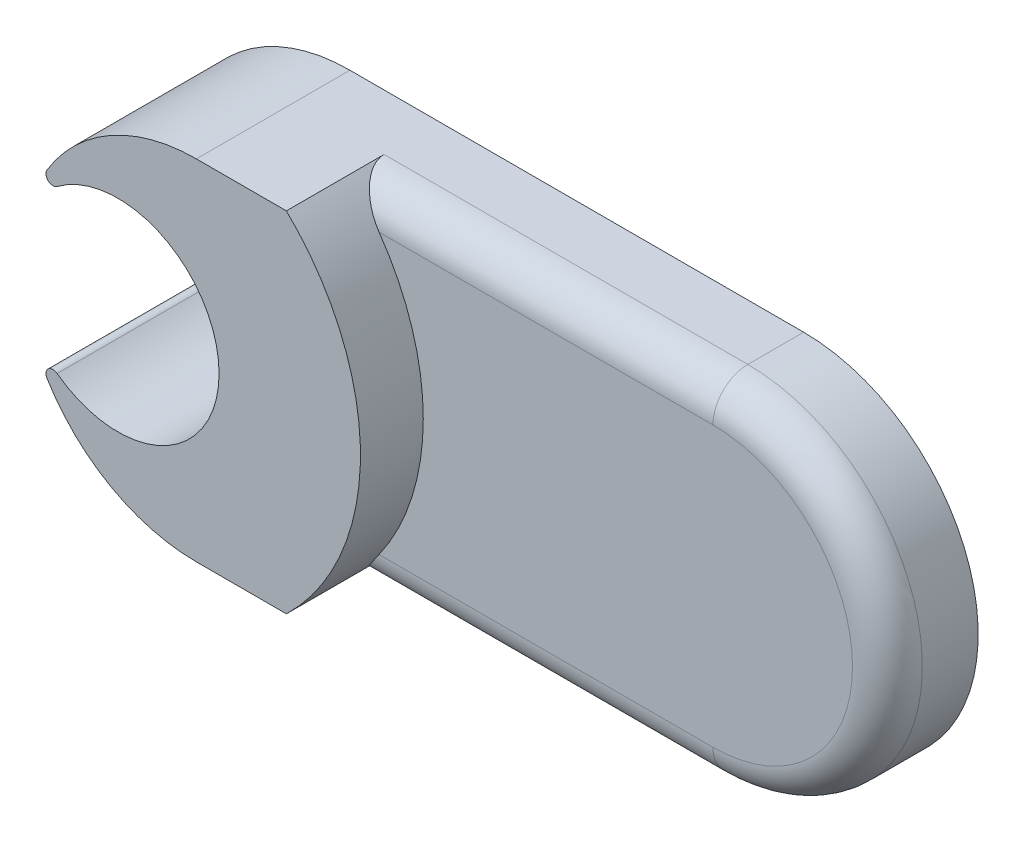
from build123d import *

# Parameters (mm, degrees)
BOSS_EXTRUDE7_DEPTH  = 2.5
BOSS_EXTRUDE8_DEPTH  = 4.4
FILLET1_R            = 0.2
FILLET2_R            = 0.2
BOSS_EXTRUDE9_DEPTH  = 4.4
BOSS_EXTRUDE10_DEPTH = 2.6
FILLET3_R            = 1


with BuildPart() as part:
    # Sketch1 → Boss-Extrude7 (new body)
    with BuildSketch(Plane.XY):
        with BuildLine():
            ThreePointArc((-8.105508314, 3.661777672), (-4.68058624, 3.096358858), (-3.111398084, 0))
            Line((-3.111398084, 0), (0, 0))
            ThreePointArc((0, 0), (-0.552546694, 2.715894232), (-2.12233973, 5))
            Line((-2.12233973, 5), (-4.700896107, 5))
            ThreePointArc((-4.700896107, 5), (-6.529982168, 4.65343359), (-8.105508314, 3.661777672))
        make_face()
    extrude(amount=BOSS_EXTRUDE7_DEPTH)

    # Sketch1_7 → Boss-Extrude8 (add)
    with BuildSketch(Plane.XY):
        with BuildLine():
            ThreePointArc((-9.512562774, 1.359361574), (-6.250479564, 2.814145815), (-4.050896107, 0))
            Line((-4.050896107, 0), (-3.111398084, 0))
            ThreePointArc((-3.111398084, 0), (-4.68058624, 3.096358858), (-8.105508314, 3.661777672))
            ThreePointArc((-8.105508314, 3.661777672), (-8.967286807, 2.607280268), (-9.512562774, 1.359361574))
        make_face()
        with BuildLine():
            Line((-3.111398084, 0), (-4.050896107, 0))
            ThreePointArc((-4.050896107, 0), (-6.250479564, -2.814145815), (-9.512562774, -1.359361574))
            ThreePointArc((-9.512562774, -1.359361574), (-8.967286807, -2.607280268), (-8.105508314, -3.661777672))
            ThreePointArc((-8.105508314, -3.661777672), (-4.68058624, -3.096358858), (-3.111398084, 0))
        make_face()
    extrude(amount=BOSS_EXTRUDE8_DEPTH)

    # Fillet1
    fillet1_edges = [part.edges().sort_by_distance(p)[0] for p in [
        (-9.512562774, -1.359361574, 2.2),
    ]]
    fillet(fillet1_edges, radius=FILLET1_R)

    # Fillet2
    fillet2_edges = [part.edges().sort_by_distance(p)[0] for p in [
        (-9.512562774, 1.359361574, 2.2),
    ]]
    fillet(fillet2_edges, radius=FILLET2_R)

    # Sketch1_8 → Boss-Extrude9 (add)
    with BuildSketch(Plane.XY):
        with BuildLine():
            ThreePointArc((-8.105508314, 3.661777672), (-4.68058624, 3.096358858), (-3.111398084, 0))
            Line((-3.111398084, 0), (0, 0))
            ThreePointArc((0, 0), (-0.552546694, 2.715894232), (-2.12233973, 5))
            Line((-2.12233973, 5), (-4.700896107, 5))
            ThreePointArc((-4.700896107, 5), (-6.529982168, 4.65343359), (-8.105508314, 3.661777672))
        make_face()
        with BuildLine():
            Line((0, 0), (-3.111398084, 0))
            ThreePointArc((-3.111398084, 0), (-4.68058624, -3.096358858), (-8.105508314, -3.661777672))
            ThreePointArc((-8.105508314, -3.661777672), (-6.529982168, -4.65343359), (-4.700896107, -5))
            Line((-4.700896107, -5), (-2.12233973, -5))
            ThreePointArc((-2.12233973, -5), (-0.552546694, -2.715894232), (0, 0))
        make_face()
    extrude(amount=BOSS_EXTRUDE9_DEPTH)

    # Sketch1_12 → Boss-Extrude10 (add)
    with BuildSketch(Plane.XY):
        with BuildLine():
            Line((8.299103893, 5), (-2.12233973, 5))
            ThreePointArc((-2.12233973, 5), (-0.552546694, 2.715894232), (0, 0))
            ThreePointArc((0, 0), (-0.552546694, -2.715894232), (-2.12233973, -5))
            Line((-2.12233973, -5), (8.299103893, -5))
            ThreePointArc((8.299103893, -5), (13.299103893, 0), (8.299103893, 5))
        make_face()
    extrude(amount=BOSS_EXTRUDE10_DEPTH)

    # Fillet3
    fillet3_edges = [part.edges().sort_by_distance(p)[0] for p in [
        (3.088382082, 5, 2.6),
        (3.088382082, -5, 2.6),
        (13.299103893, 0, 2.6),
    ]]
    fillet(fillet3_edges, radius=FILLET3_R)


solid = part.part
